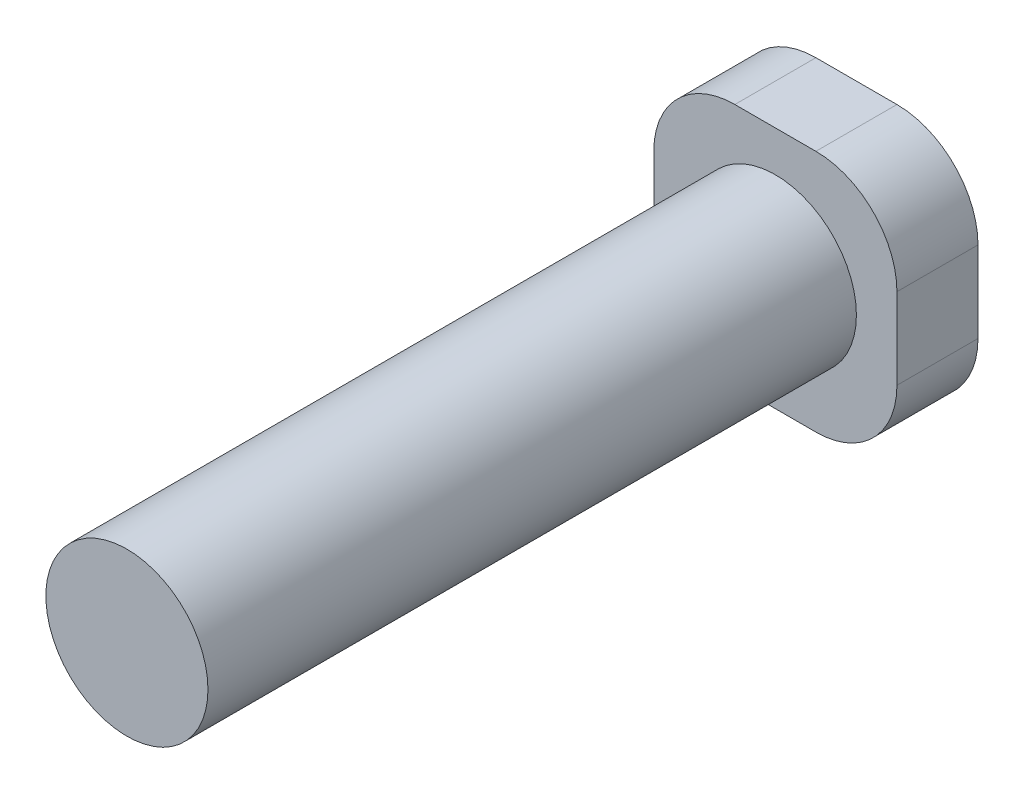
from build123d import *

# Parameters (mm, degrees)
BOSS_EXTRUDE2_DEPTH = 1
SKETCH2_R           = 1
BOSS_EXTRUDE3_DEPTH = 8


with BuildPart() as part:
    # Sketch1 → Boss-Extrude2 (new body)
    with BuildSketch(Plane.XY):
        with BuildLine():
            Line((-0.5, -1.5), (0.5, -1.5))
            ThreePointArc((0.5, -1.5), (1.207106781, -1.207106781), (1.5, -0.5))
            Line((1.5, -0.5), (1.5, 0.5))
            ThreePointArc((1.5, 0.5), (1.207106781, 1.207106781), (0.5, 1.5))
            Line((0.5, 1.5), (-0.5, 1.5))
            ThreePointArc((-0.5, 1.5), (-1.207106781, 1.207106781), (-1.5, 0.5))
            Line((-1.5, 0.5), (-1.5, -0.5))
            ThreePointArc((-1.5, -0.5), (-1.207106781, -1.207106781), (-0.5, -1.5))
        make_face()
    extrude(amount=BOSS_EXTRUDE2_DEPTH)

    # Sketch2 → Boss-Extrude3 (add)
    with BuildSketch(Plane.XY.offset(1)):
        Circle(SKETCH2_R)
    extrude(amount=BOSS_EXTRUDE3_DEPTH)


solid = part.part
